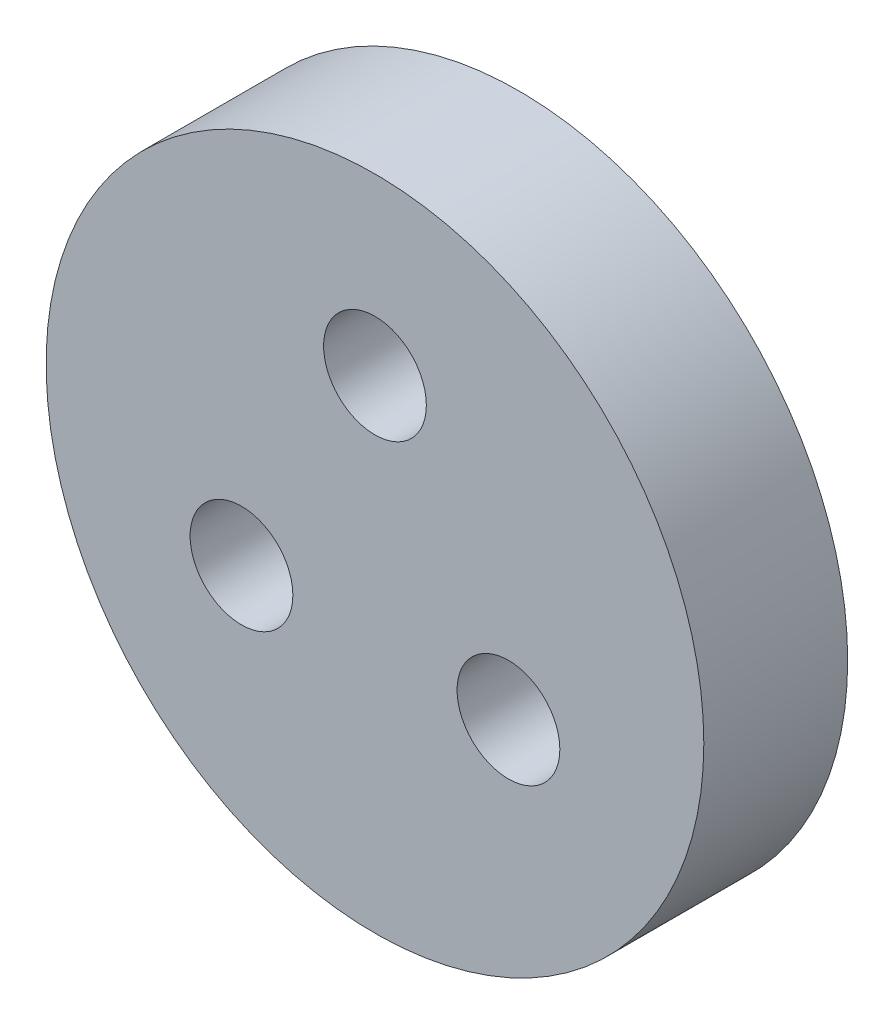
from build123d import *

# Parameters (mm, degrees)
SKETCH1_R           = 8
SKETCH1_R_2         = 6
SKETCH1_R_3         = 1.25
SKETCH1_R_4         = 1.5
BOSS_EXTRUDE1_DEPTH = 3.5
SKETCH2_R           = 1.5
BOSS_EXTRUDE2_DEPTH = 2


with BuildPart() as part:
    # Sketch1 → Boss-Extrude1 (new body)
    with BuildSketch(Plane.XY):
        with Locations((-43.483141232, -69.989052064)):
            Circle(SKETCH1_R)
        with Locations((-43.483141232, -69.989052064)):
            Circle(SKETCH1_R_2, mode=Mode.SUBTRACT)
        with Locations((-43.483141232, -69.989052064)):
            Circle(SKETCH1_R)
        with Locations((-40.235545968, -71.864052064)):
            Circle(SKETCH1_R_3, mode=Mode.SUBTRACT)
        with Locations((-46.730736496, -71.864052064)):
            Circle(SKETCH1_R_3, mode=Mode.SUBTRACT)
        with Locations((-43.483141232, -66.239052064)):
            Circle(SKETCH1_R_3, mode=Mode.SUBTRACT)
        with Locations((-43.483141232, -69.989052064)):
            Circle(SKETCH1_R_4, mode=Mode.SUBTRACT)
        with Locations((-43.483141232, -69.989052064)):
            Circle(SKETCH1_R_4)
    extrude(amount=BOSS_EXTRUDE1_DEPTH)

    # Sketch2 → Boss-Extrude2 (add)
    with BuildSketch(Plane(origin=(0, 0, 0), x_dir=(-1, 0, 0), z_dir=(0, 0, -1))):
        with Locations((43.483141232, -69.989052064)):
            Circle(SKETCH2_R)
    extrude(amount=BOSS_EXTRUDE2_DEPTH)


solid = part.part
